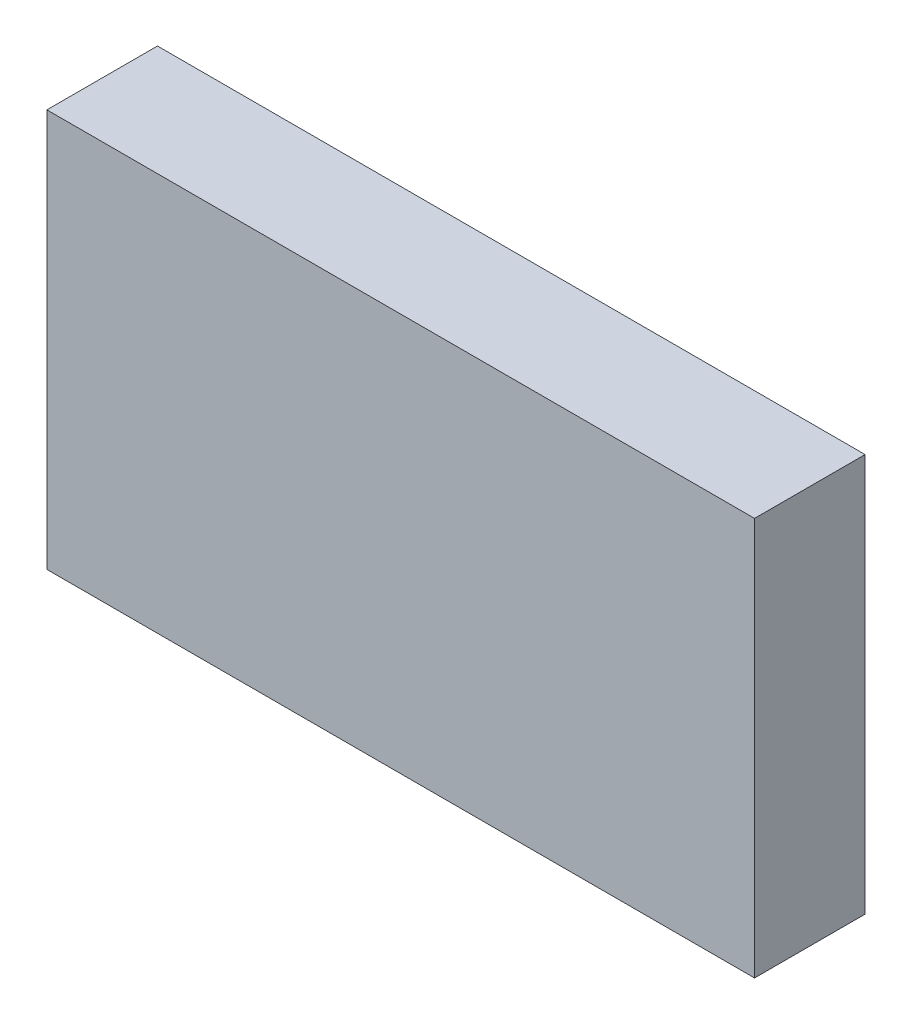
from build123d import *

# Parameters (mm, degrees)
SKETCH_1_W      = 32
SKETCH_1_H      = 18
EXTRUDE_1_DEPTH = 5


with BuildPart() as part:
    # 草圖1 → 填料-伸長1 (new body)
    with BuildSketch(Plane.XY):
        Rectangle(SKETCH_1_W, SKETCH_1_H)
    extrude(amount=EXTRUDE_1_DEPTH)


solid = part.part
